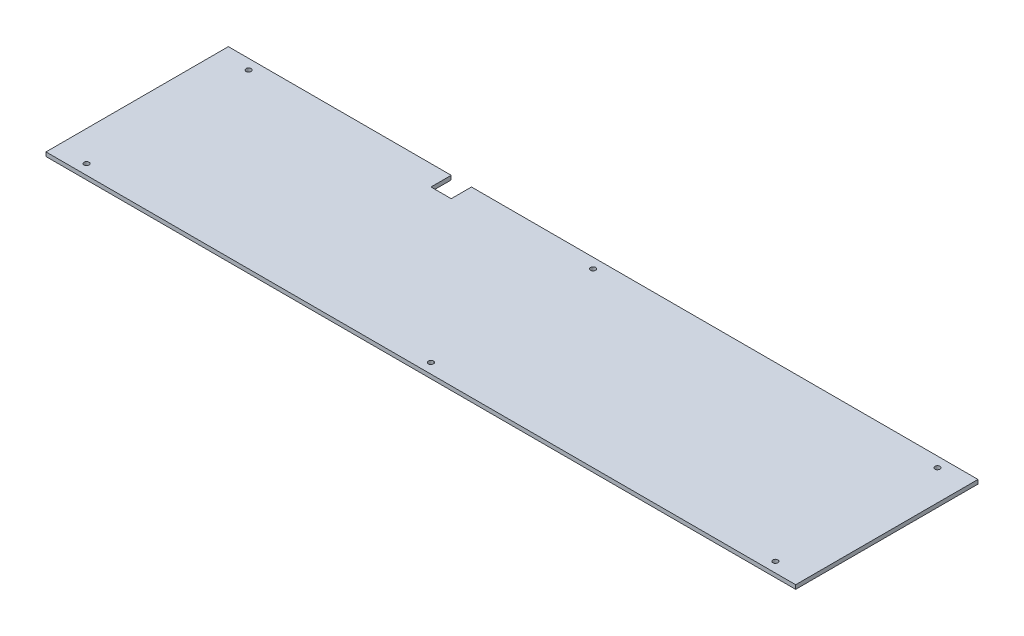
from build123d import *

# Parameters (mm, degrees)
SKETCH1_R           = 2.5
BOSS_EXTRUDE1_DEPTH = 4


with BuildPart() as part:
    # Sketch1 → Boss-Extrude1 (new body)
    with BuildSketch(Plane(origin=(0, 0, 0), x_dir=(1, 0, 0), z_dir=(0, 1, 0))):
        Polygon((-370, -90), (370, -90), (370, 90), (-130, 90), (-130, 70), (-150, 70), (-150, 90), (-370, 90), align=None)
        with Locations((-340, 80)):
            Circle(SKETCH1_R, mode=Mode.SUBTRACT)
        with Locations((0, 80)):
            Circle(SKETCH1_R, mode=Mode.SUBTRACT)
        with Locations((340, 80)):
            Circle(SKETCH1_R, mode=Mode.SUBTRACT)
        with Locations((-340, -80)):
            Circle(SKETCH1_R, mode=Mode.SUBTRACT)
        with Locations((0, -80)):
            Circle(SKETCH1_R, mode=Mode.SUBTRACT)
        with Locations((340, -80)):
            Circle(SKETCH1_R, mode=Mode.SUBTRACT)
    extrude(amount=BOSS_EXTRUDE1_DEPTH)


solid = part.part
